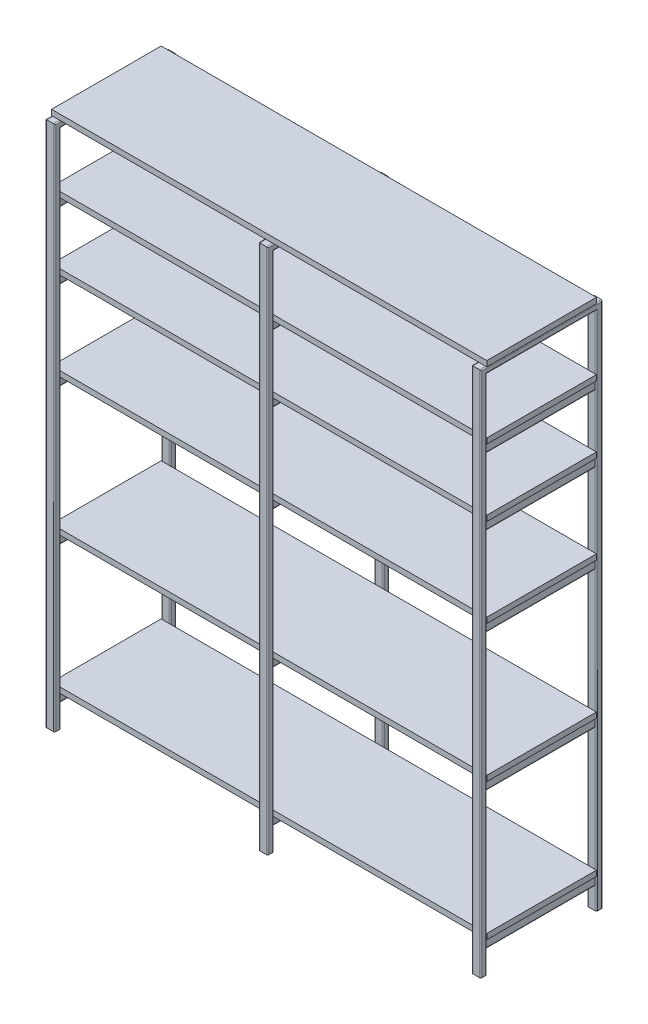
from build123d import *

# Parameters (mm, degrees)
MATRIZL2_COUNT          = 3
MATRIZL2_PITCH          = 450
MATRIZL4_COUNT          = 2
MATRIZL4_PITCH          = 290
MATRIZL6_COUNT          = 2
MATRIZL6_PITCH          = 220
MATRIZL1_COUNT          = 3
MATRIZL1_PITCH          = 700
CROQUIS6_W              = 360
CROQUIS6_H              = 18
SALIENTE_EXTRUIR1_DEPTH = 715
MATRIZL3_COUNT          = 3
MATRIZL3_PITCH          = 450
MATRIZL5_COUNT          = 2
MATRIZL5_PITCH          = 290
MATRIZL7_COUNT          = 3
MATRIZL7_PITCH          = 220


with BuildPart() as part:
    # Barrer-Lámina1: sweep along a path in Croquis1
    with BuildLine(Plane(origin=(0, 0, 0), x_dir=(0, 0, -1), z_dir=(1, 0, 0))) as barrer_l_mina1_path:
        Line((-200, 0), (-200, 1730))
        Line((-200, 1730), (200, 1730))
        Line((200, 1730), (200, 0))
    # Croquis2 → Barrer-Lámina1 (sweep)
    with BuildSketch(Plane(origin=(0, 0, 0), x_dir=(1, 0, 0), z_dir=(0, 1, 0))):
        with BuildLine():
            Line((15, 196), (15, 184))
            ThreePointArc((15, 184), (13.828427125, 181.171572875), (11, 180))
            Line((11, 180), (-11, 180))
            ThreePointArc((-11, 180), (-13.828427125, 181.171572875), (-15, 184))
            Line((-15, 184), (-15, 196))
            ThreePointArc((-15, 196), (-13.828427125, 198.828427125), (-11, 200))
            Line((-11, 200), (11, 200))
            ThreePointArc((11, 200), (13.828427125, 198.828427125), (15, 196))
        make_face()
        with BuildLine():
            Line((13, 196), (13, 184))
            ThreePointArc((13, 184), (12.414213562, 182.585786438), (11, 182))
            Line((11, 182), (-11, 182))
            ThreePointArc((-11, 182), (-12.414213562, 182.585786438), (-13, 184))
            Line((-13, 184), (-13, 196))
            ThreePointArc((-13, 196), (-12.414213562, 197.414213562), (-11, 198))
            Line((-11, 198), (11, 198))
            ThreePointArc((11, 198), (12.414213562, 197.414213562), (13, 196))
        make_face(mode=Mode.SUBTRACT)
    sweep(path=barrer_l_mina1_path.line, transition=Transition.RIGHT)


with BuildPart() as body_2:
    # Barrer-Lámina2: sweep along a path in Croquis3
    with BuildLine(Plane(origin=(0, 0, 0), x_dir=(0, 0, -1), z_dir=(1, 0, 0))) as barrer_l_mina2_path:
        Line((-180, 100), (180, 100))
    # Croquis5 → Barrer-Lámina2 (sweep)
    with BuildSketch(Plane.XY):
        with BuildLine():
            Line((10, 96), (10, 74))
            ThreePointArc((10, 74), (8.828427125, 71.171572875), (6, 70))
            Line((6, 70), (-6, 70))
            ThreePointArc((-6, 70), (-8.828427125, 71.171572875), (-10, 74))
            Line((-10, 74), (-10, 96))
            ThreePointArc((-10, 96), (-8.828427125, 98.828427125), (-6, 100))
            Line((-6, 100), (6, 100))
            ThreePointArc((6, 100), (8.828427125, 98.828427125), (10, 96))
        make_face()
        with BuildLine():
            Line((8, 96), (8, 74))
            ThreePointArc((8, 74), (7.414213562, 72.585786438), (6, 72))
            Line((6, 72), (-6, 72))
            ThreePointArc((-6, 72), (-7.414213562, 72.585786438), (-8, 74))
            Line((-8, 74), (-8, 96))
            ThreePointArc((-8, 96), (-7.414213562, 97.414213562), (-6, 98))
            Line((-6, 98), (6, 98))
            ThreePointArc((6, 98), (7.414213562, 97.414213562), (8, 96))
        make_face(mode=Mode.SUBTRACT)
    sweep(path=barrer_l_mina2_path.line)


with BuildPart() as matrizl2_1:
    # MatrizL2: pattern copy
    add(body_2.part.moved(Location(Vector(0, 1, 0) * (1 * MATRIZL2_PITCH))))


with BuildPart() as matrizl2_2:
    # MatrizL2: pattern copy
    add(body_2.part.moved(Location(Vector(0, 1, 0) * (2 * MATRIZL2_PITCH))))


with BuildPart() as matrizl4_1:
    # MatrizL4: pattern copy
    add(matrizl2_2.part.moved(Location(Vector(0, 1, 0) * (1 * MATRIZL4_PITCH))))


with BuildPart() as matrizl6_1:
    # MatrizL6: pattern copy
    add(matrizl4_1.part.moved(Location(Vector(0, 1, 0) * (1 * MATRIZL6_PITCH))))


with BuildPart() as matrizl1_1:
    # MatrizL1: pattern copy
    add(part.part.moved(Location(Vector(-1, 0, 0) * (1 * MATRIZL1_PITCH))))


with BuildPart() as matrizl1_2:
    # MatrizL1: pattern copy
    add(part.part.moved(Location(Vector(-1, 0, 0) * (2 * MATRIZL1_PITCH))))


with BuildPart() as matrizl1_3:
    # MatrizL1: pattern copy
    add(body_2.part.moved(Location(Vector(-1, 0, 0) * (1 * MATRIZL1_PITCH))))


with BuildPart() as matrizl1_4:
    # MatrizL1: pattern copy
    add(body_2.part.moved(Location(Vector(-1, 0, 0) * (2 * MATRIZL1_PITCH))))


with BuildPart() as matrizl1_5:
    # MatrizL1: pattern copy
    add(matrizl2_1.part.moved(Location(Vector(-1, 0, 0) * (1 * MATRIZL1_PITCH))))


with BuildPart() as matrizl1_6:
    # MatrizL1: pattern copy
    add(matrizl2_1.part.moved(Location(Vector(-1, 0, 0) * (2 * MATRIZL1_PITCH))))


with BuildPart() as matrizl1_7:
    # MatrizL1: pattern copy
    add(matrizl2_2.part.moved(Location(Vector(-1, 0, 0) * (1 * MATRIZL1_PITCH))))


with BuildPart() as matrizl1_8:
    # MatrizL1: pattern copy
    add(matrizl2_2.part.moved(Location(Vector(-1, 0, 0) * (2 * MATRIZL1_PITCH))))


with BuildPart() as matrizl1_9:
    # MatrizL1: pattern copy
    add(matrizl4_1.part.moved(Location(Vector(-1, 0, 0) * (1 * MATRIZL1_PITCH))))


with BuildPart() as matrizl1_10:
    # MatrizL1: pattern copy
    add(matrizl4_1.part.moved(Location(Vector(-1, 0, 0) * (2 * MATRIZL1_PITCH))))


with BuildPart() as matrizl1_11:
    # MatrizL1: pattern copy
    add(matrizl6_1.part.moved(Location(Vector(-1, 0, 0) * (1 * MATRIZL1_PITCH))))


with BuildPart() as matrizl1_12:
    # MatrizL1: pattern copy
    add(matrizl6_1.part.moved(Location(Vector(-1, 0, 0) * (2 * MATRIZL1_PITCH))))


with BuildPart() as body_19:
    # Croquis6 → Saliente-Extruir1 (new, symmetric)
    with BuildSketch(Plane(origin=(-700, 0, 0), x_dir=(0, 0, -1), z_dir=(1, 0, 0))):
        with Locations((0, 109)):
            Rectangle(CROQUIS6_W, CROQUIS6_H)
    extrude(amount=SALIENTE_EXTRUIR1_DEPTH, both=True)


with BuildPart() as matrizl3_1:
    # MatrizL3: pattern copy
    add(body_19.part.moved(Location(Vector(0, 1, 0) * (1 * MATRIZL3_PITCH))))


with BuildPart() as matrizl3_2:
    # MatrizL3: pattern copy
    add(body_19.part.moved(Location(Vector(0, 1, 0) * (2 * MATRIZL3_PITCH))))


with BuildPart() as matrizl5_1:
    # MatrizL5: pattern copy
    add(matrizl3_2.part.moved(Location(Vector(0, 1, 0) * (1 * MATRIZL5_PITCH))))


with BuildPart() as matrizl7_1:
    # MatrizL7: pattern copy
    add(matrizl5_1.part.moved(Location(Vector(0, 1, 0) * (1 * MATRIZL7_PITCH))))


with BuildPart() as matrizl7_2:
    # MatrizL7: pattern copy
    add(matrizl5_1.part.moved(Location(Vector(0, 1, 0) * (2 * MATRIZL7_PITCH))))


solid = Compound([part.part, body_2.part, matrizl2_1.part, matrizl2_2.part, matrizl4_1.part, matrizl6_1.part, matrizl1_1.part, matrizl1_2.part, matrizl1_3.part, matrizl1_4.part, matrizl1_5.part, matrizl1_6.part, matrizl1_7.part, matrizl1_8.part, matrizl1_9.part, matrizl1_10.part, matrizl1_11.part, matrizl1_12.part, body_19.part, matrizl3_1.part, matrizl3_2.part, matrizl5_1.part, matrizl7_1.part, matrizl7_2.part])
